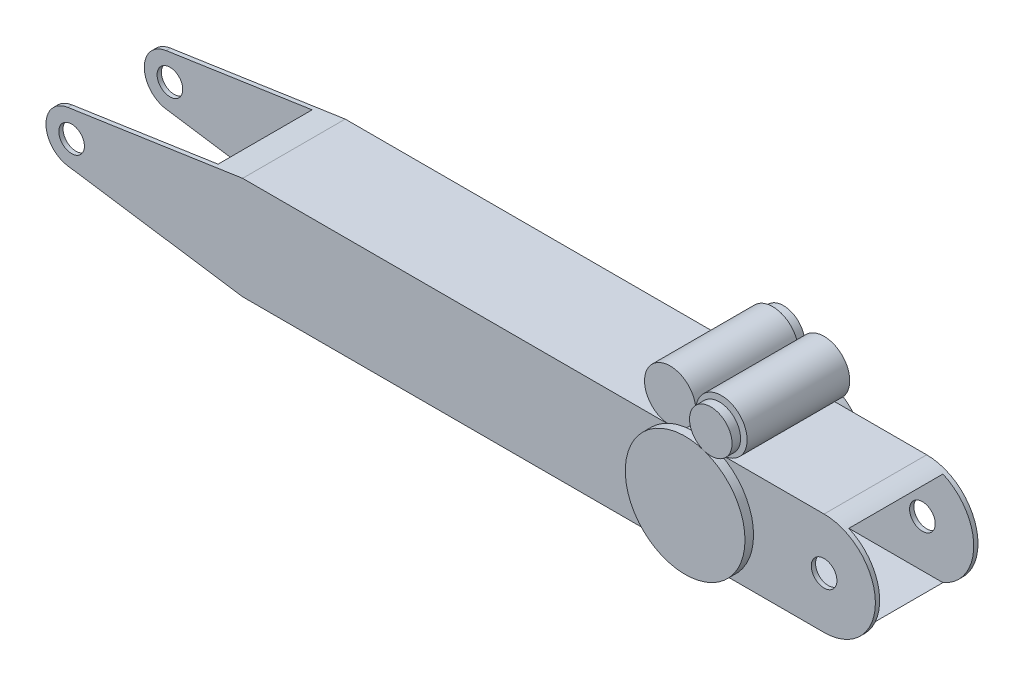
from build123d import *

# Parameters (mm, degrees)
SKETCH1_R               = 9.525
BOSS_EXTRUDE1_DEPTH     = 38.1
SKETCH2_W               = 69.85
SKETCH2_H               = 69.85
CUT_EXTRUDE1_DEPTH      = 318.5
CUT_EXTRUDE1_DEPTH_BACK = 299.45
SKETCH3_R               = 19.05
BOSS_EXTRUDE2_DEPTH     = 76.2
BOSS_EXTRUDE2_2_DEPTH   = 76.2
BOSS_EXTRUDE3_START     = 1.5875
SKETCH4_R               = 44.45
BOSS_EXTRUDE3_DEPTH     = 6.35
SKETCH4_R_2             = 15.791389426
BOSS_EXTRUDE3_2_DEPTH   = 6.35
BOSS_EXTRUDE4_START     = 1.5875
SKETCH5_R               = 15.791389426
BOSS_EXTRUDE4_DEPTH     = 6.35


with BuildPart() as part:
    # Sketch1 → Boss-Extrude1 (new body, symmetric)
    with BuildSketch(Plane.XY):
        with BuildLine():
            Line((-282.195625509, 18.843751697), (-152.4, 38.1))
            Line((-152.4, 38.1), (279.4, 38.1))
            ThreePointArc((279.4, 38.1), (317.5, 0), (279.4, -38.1))
            Line((279.4, -38.1), (-152.4, -38.1))
            Line((-152.4, -38.1), (-282.195625509, -18.843751697))
            ThreePointArc((-282.195625509, -18.843751697), (-298.45, 0), (-282.195625509, 18.843751697))
        make_face()
        with Locations((279.4, 0)):
            Circle(SKETCH1_R, mode=Mode.SUBTRACT)
        with Locations((-279.4, 0)):
            Circle(SKETCH1_R, mode=Mode.SUBTRACT)
    extrude(amount=BOSS_EXTRUDE1_DEPTH, both=True)

    # Sketch2 → Cut-Extrude1 (cut, two sides)
    with BuildSketch(Plane(origin=(0, 0, 0), x_dir=(0, 0, -1), z_dir=(1, 0, 0))) as cut_extrude1_sk:
        Rectangle(SKETCH2_W, SKETCH2_H)
    extrude(amount=CUT_EXTRUDE1_DEPTH, mode=Mode.SUBTRACT)
    extrude(cut_extrude1_sk.sketch, amount=-CUT_EXTRUDE1_DEPTH_BACK, mode=Mode.SUBTRACT)


with BuildPart() as body_2:
    # Sketch3 → Boss-Extrude2 (new body)
    with BuildSketch(Plane.XY.offset(38.1)):
        with Locations((165.1, 57.15)):
            Circle(SKETCH3_R)
    extrude(amount=-BOSS_EXTRUDE2_DEPTH)


with BuildPart() as body_3:
    # Sketch3 → Boss-Extrude2 2 (new body)
    with BuildSketch(Plane.XY.offset(38.1)):
        with Locations((203.2, 57.15)):
            Circle(SKETCH3_R)
    extrude(amount=-BOSS_EXTRUDE2_2_DEPTH)


with BuildPart() as body_4:
    # Sketch4 → Boss-Extrude3 (new body)
    with BuildSketch(Plane.XY.offset(38.1).offset(BOSS_EXTRUDE3_START)):
        with Locations((184.15, 0)):
            Circle(SKETCH4_R)
    extrude(amount=BOSS_EXTRUDE3_DEPTH)


with BuildPart() as body_5:
    # Sketch4 → Boss-Extrude3 2 (new body)
    with BuildSketch(Plane.XY.offset(38.1).offset(BOSS_EXTRUDE3_START)):
        with Locations((203.2, 57.15)):
            Circle(SKETCH4_R_2)
    extrude(amount=BOSS_EXTRUDE3_2_DEPTH)


with BuildPart() as body_6:
    # Mirror1: mirrored copy
    add(body_4.part.mirror(Plane.XY))


with BuildPart() as body_7:
    # Sketch5 → Boss-Extrude4 (new body)
    with BuildSketch(Plane(origin=(0, 0, -38.1), x_dir=(-1, 0, 0), z_dir=(0, 0, -1)).offset(BOSS_EXTRUDE4_START)):
        with Locations((-165.1, 57.15)):
            Circle(SKETCH5_R)
    extrude(amount=BOSS_EXTRUDE4_DEPTH)


solid = Compound([part.part, body_2.part, body_3.part, body_4.part, body_5.part, body_6.part, body_7.part])
